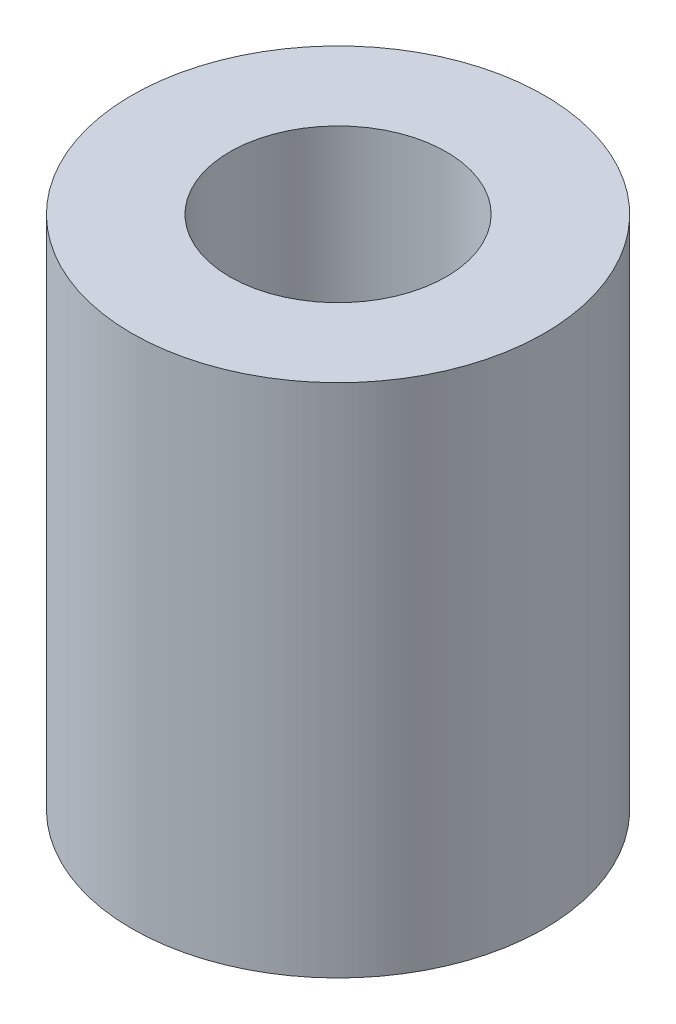
from build123d import *

# Parameters (mm, degrees)
SKETCH1_R           = 4
SKETCH1_R_2         = 2.1
BOSS_EXTRUDE1_DEPTH = 10


with BuildPart() as part:
    # Sketch1 → Boss-Extrude1 (new body)
    with BuildSketch(Plane(origin=(0, 0, 0), x_dir=(1, 0, 0), z_dir=(0, 1, 0))):
        Circle(SKETCH1_R)
        Circle(SKETCH1_R_2, mode=Mode.SUBTRACT)
    extrude(amount=BOSS_EXTRUDE1_DEPTH)


solid = part.part
